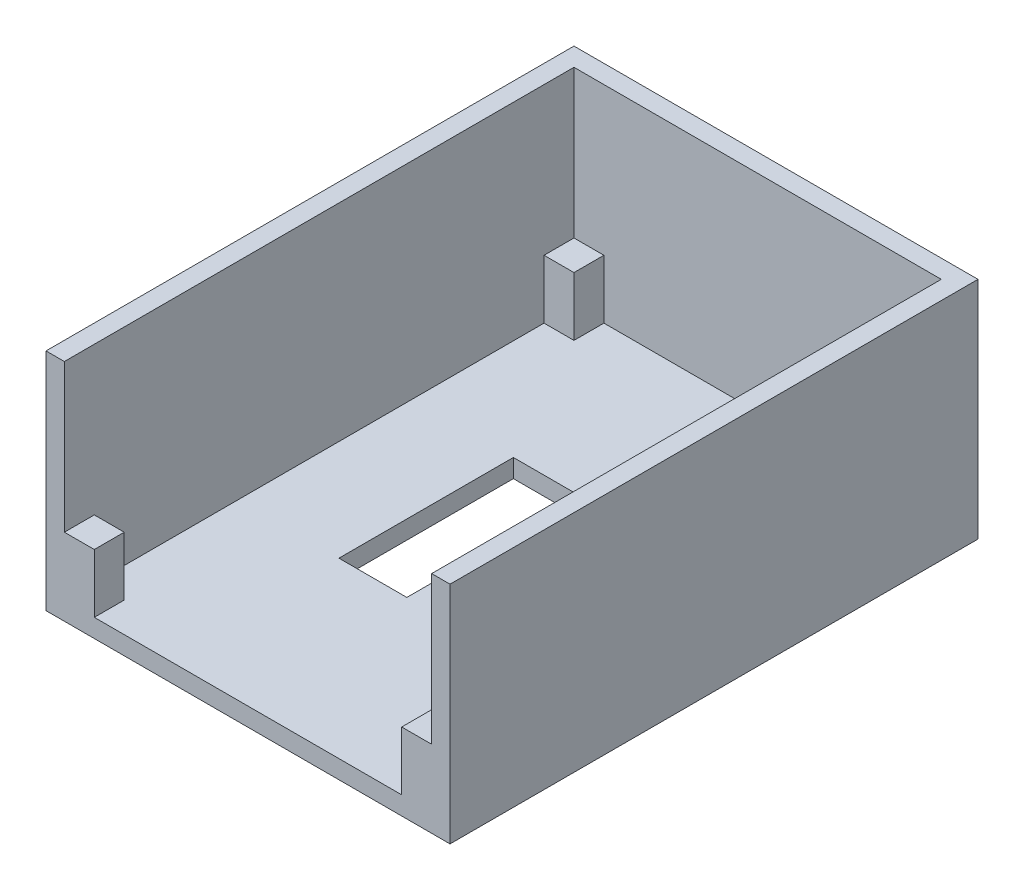
from build123d import *

# Parameters (mm, degrees)
SKETCH1_W           = 50.8
SKETCH1_H           = 70.485
BOSS_EXTRUDE1_DEPTH = 2.54
BOSS_EXTRUDE2_DEPTH = 31.115
SKETCH6_W           = 4.1402
SKETCH6_H           = 4.1402
BOSS_EXTRUDE3_DEPTH = 8.128
SKETCH8_W           = 9.398
SKETCH8_H           = 24.13
CUT_EXTRUDE2_DEPTH  = 3.54


with BuildPart() as part:
    # Sketch1 → Boss-Extrude1 (new body)
    with BuildSketch(Plane(origin=(0, 0, 0), x_dir=(1, 0, 0), z_dir=(0, 1, 0))):
        Rectangle(SKETCH1_W, SKETCH1_H)
    extrude(amount=BOSS_EXTRUDE1_DEPTH)

    # Sketch5 → Boss-Extrude2 (add)
    with BuildSketch(Plane(origin=(0, 0, 0), x_dir=(1, 0, 0), z_dir=(0, 1, 0))):
        Polygon((27.94, -35.2425), (27.94, 37.7825), (-27.94, 37.7825), (-27.94, -35.2425), (-25.4, -35.2425), (-25.4, 35.2425), (25.4, 35.2425), (25.4, -35.2425), align=None)
    extrude(amount=BOSS_EXTRUDE2_DEPTH)

    # Sketch6 → Boss-Extrude3 (add)
    with BuildSketch(Plane(origin=(0, 2.54, 0), x_dir=(1, 0, 0), z_dir=(0, 1, 0))):
        with Locations((-23.3299, 33.1724)):
            Rectangle(SKETCH6_W, SKETCH6_H)
        with Locations((23.3299, 33.1724)):
            Rectangle(SKETCH6_W, SKETCH6_H)
        with Locations((23.3299, -33.1724)):
            Rectangle(SKETCH6_W, SKETCH6_H)
        with Locations((-23.3299, -33.1724)):
            Rectangle(SKETCH6_W, SKETCH6_H)
    extrude(amount=BOSS_EXTRUDE3_DEPTH)

    # Sketch8 → Cut-Extrude2 (cut, through all)
    with BuildSketch(Plane(origin=(0, 2.54, 0), x_dir=(1, 0, 0), z_dir=(0, 1, 0))):
        with Locations((-6.731, 0.8255)):
            Rectangle(SKETCH8_W, SKETCH8_H)
    extrude(amount=-CUT_EXTRUDE2_DEPTH, mode=Mode.SUBTRACT)


solid = part.part
